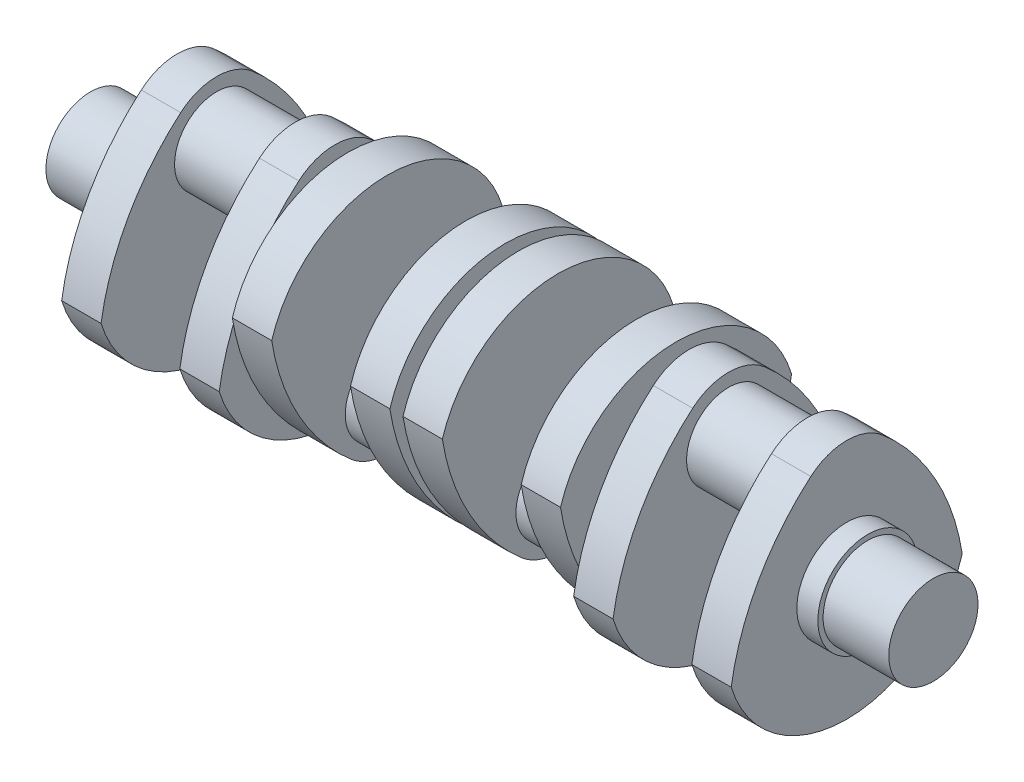
from build123d import *

# Parameters (mm, degrees)
SKETCH2_R           = 17
BOSS_EXTRUDE1_DEPTH = 25
SKETCH2_3_R         = 19
SKETCH2_3_R_2       = 17
BOSS_EXTRUDE2_DEPTH = 8
BOSS_EXTRUDE3_DEPTH = 15
SKETCH4_R           = 16
BOSS_EXTRUDE4_DEPTH = 15
SKETCH5_R           = 17
BOSS_EXTRUDE5_DEPTH = 5
BOSS_EXTRUDE6_DEPTH = 15
SKETCH7_R           = 16
BOSS_EXTRUDE7_DEPTH = 30
BOSS_EXTRUDE8_DEPTH = 15
SKETCH9_R           = 17
BOSS_EXTRUDE9_DEPTH = 2.5


with BuildPart() as part:
    # Sketch2 → Boss-Extrude1 (new body)
    with BuildSketch(Plane(origin=(0, 0, 0), x_dir=(0, 0, -1), z_dir=(1, 0, 0))):
        Circle(SKETCH2_R)
    extrude(amount=-BOSS_EXTRUDE1_DEPTH)

    # Sketch2_3 → Boss-Extrude2 (add)
    with BuildSketch(Plane(origin=(0, 0, 0), x_dir=(0, 0, -1), z_dir=(1, 0, 0))):
        Circle(SKETCH2_3_R)
        Circle(SKETCH2_3_R_2, mode=Mode.SUBTRACT)
        Circle(SKETCH2_3_R_2)
    extrude(amount=BOSS_EXTRUDE2_DEPTH)

    # Sketch3 → Boss-Extrude3 (add)
    with BuildSketch(Plane(origin=(8, 0, 0), x_dir=(0, 0, -1), z_dir=(1, 0, 0))):
        with BuildLine():
            ThreePointArc((13.668094758, 40.943123461), (0, 46), (-13.668094758, 40.943123461))
            ThreePointArc((-13.668094758, 40.943123461), (-33.683444249, 16.469257624), (-44, -13.416407865))
            ThreePointArc((-44, -13.416407865), (0, -46), (44, -13.416407865))
            ThreePointArc((44, -13.416407865), (33.683444249, 16.469257624), (13.668094758, 40.943123461))
        make_face()
    boss_extrude3 = extrude(amount=BOSS_EXTRUDE3_DEPTH)

    # Sketch4 → Boss-Extrude4 (add)
    with BuildSketch(Plane(origin=(23, 0, 0), x_dir=(0, 0, -1), z_dir=(1, 0, 0))):
        with Locations(Location((0, 25, 0), (0, 0, 180))):
            Circle(SKETCH4_R)
    boss_extrude4 = extrude(amount=BOSS_EXTRUDE4_DEPTH)

    # Mirror1: Boss-Extrude3, Boss-Extrude4 across plane
    add(boss_extrude3.mirror(Plane(origin=(38, 25, 0), x_dir=(0, 0, 1), z_dir=(1, 0, 0))))
    add(boss_extrude4.mirror(Plane(origin=(38, 25, 0), x_dir=(0, 0, 1), z_dir=(1, 0, 0))))

    # Sketch5 → Boss-Extrude5 (add)
    with BuildSketch(Plane(origin=(68, 0, 0), x_dir=(0, 0, -1), z_dir=(1, 0, 0))):
        Circle(SKETCH5_R)
    extrude(amount=BOSS_EXTRUDE5_DEPTH)

    # Sketch6 → Boss-Extrude6 (add)
    with BuildSketch(Plane(origin=(73, 0, 0), x_dir=(0, 0, -1), z_dir=(1, 0, 0))):
        with BuildLine():
            ThreePointArc((-13.668094758, -40.943123461), (0, -46), (13.668094758, -40.943123461))
            ThreePointArc((13.668094758, -40.943123461), (33.683444249, -16.469257624), (44, 13.416407865))
            ThreePointArc((44, 13.416407865), (0, 46), (-44, 13.416407865))
            ThreePointArc((-44, 13.416407865), (-33.683444249, -16.469257624), (-13.668094758, -40.943123461))
        make_face()
    extrude(amount=BOSS_EXTRUDE6_DEPTH)

    # Sketch7 → Boss-Extrude7 (add)
    with BuildSketch(Plane(origin=(88, 0, 0), x_dir=(0, 0, -1), z_dir=(1, 0, 0))):
        with Locations((0, -25)):
            Circle(SKETCH7_R)
    extrude(amount=BOSS_EXTRUDE7_DEPTH)

    # Sketch8 → Boss-Extrude8 (add)
    with BuildSketch(Plane(origin=(118, 0, 0), x_dir=(0, 0, -1), z_dir=(1, 0, 0))):
        with BuildLine():
            ThreePointArc((-13.668094758, -40.943123461), (0, -46), (13.668094758, -40.943123461))
            ThreePointArc((13.668094758, -40.943123461), (33.683444249, -16.469257624), (44, 13.416407865))
            ThreePointArc((44, 13.416407865), (0, 46), (-44, 13.416407865))
            ThreePointArc((-44, 13.416407865), (-33.683444249, -16.469257624), (-13.668094758, -40.943123461))
        make_face()
    extrude(amount=BOSS_EXTRUDE8_DEPTH)

    # Sketch9 → Boss-Extrude9 (add)
    with BuildSketch(Plane(origin=(133, 0, 0), x_dir=(0, 0, -1), z_dir=(1, 0, 0))):
        Circle(SKETCH9_R)
    extrude(amount=BOSS_EXTRUDE9_DEPTH)

    # Mirror2: part across plane


with BuildPart() as part_1:
    add(part.part)
    add(part.part.mirror(Plane(origin=(135.5, 0, 0), x_dir=(0, 0, 1), z_dir=(1, 0, 0))))


solid = part_1.part
